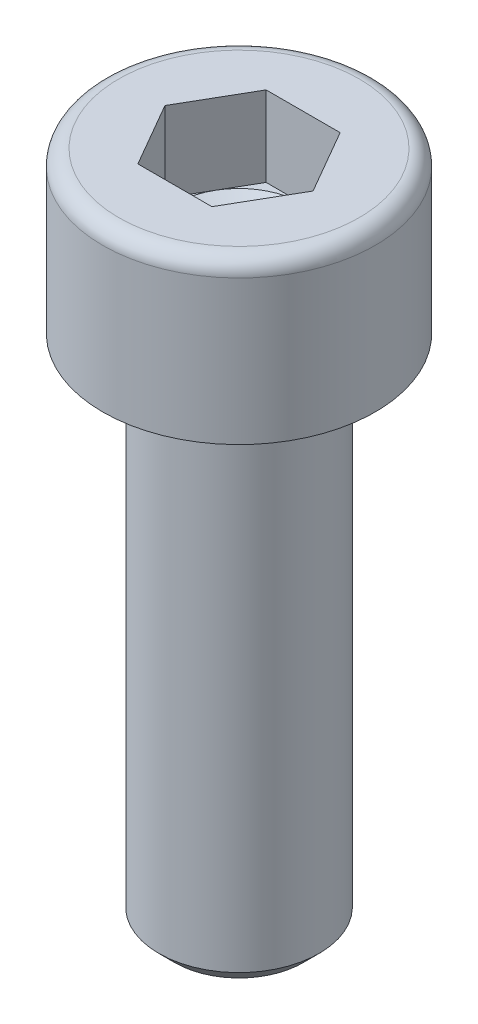
from build123d import *

# Parameters (mm, degrees)
ESQUISSE2_R             = 2.5
BASE_EXTRUSION_DEPTH    = 16
CHANFREIN1_SIZE         = 0.5
ENL_V_MAT_EXTRU_1_DEPTH = 2.5


with BuildPart() as part:
    # Esquisse2 → Base-Extrusion (new body)
    with BuildSketch(Plane(origin=(0, 0, 0), x_dir=(1, 0, 0), z_dir=(0, 1, 0))):
        with Locations(Location((0, 0, 0), (0, 0, 270))):  # turned: the seam where the file's is
            Circle(ESQUISSE2_R)
    extrude(amount=-BASE_EXTRUSION_DEPTH)

    # Chanfrein1
    chanfrein1_edges = [part.edges().sort_by_distance(p)[0] for p in [
        (0, -16, -2.5),
    ]]
    chamfer(chanfrein1_edges, length=CHANFREIN1_SIZE)

    # Esquisse5 → Boss.-Révol.1 (revolve)
    with BuildSketch(Plane.XY, mode=Mode.PRIVATE) as boss_r_vol_1_sk:
        with BuildLine():
            Line((2, 5), (2, 2.5))
            Line((2, 2.5), (0, 1.345299462))
            Line((0, 1.345299462), (0, 0))
            Line((0, 0), (4.25, 0))
            Line((4.25, 0), (4.25, 4.5))
            ThreePointArc((4.25, 4.5), (4.103553391, 4.853553391), (3.75, 5))
            Line((3.75, 5), (2, 5))
        make_face()
    revolve(boss_r_vol_1_sk.sketch.rotate(Axis((0, 5, 0), (0, -1, 0)), 90), axis=Axis((0, 5, 0), (0, -1, 0)))  # turned: the seam where the file's is

    # Esquisse7 → Enlèv. mat.-Extru.1 (cut)
    with BuildSketch(Plane(origin=(0, 5, 0), x_dir=(-1, 0, 0), z_dir=(0, 1, 0))):
        Polygon((1.154700538, 2), (-1.154700538, 2), (-2.309401077, 0), (-1.154700538, -2), (1.154700538, -2), (2.309401077, 0), align=None)
    extrude(amount=-ENL_V_MAT_EXTRU_1_DEPTH, mode=Mode.SUBTRACT)


solid = part.part
